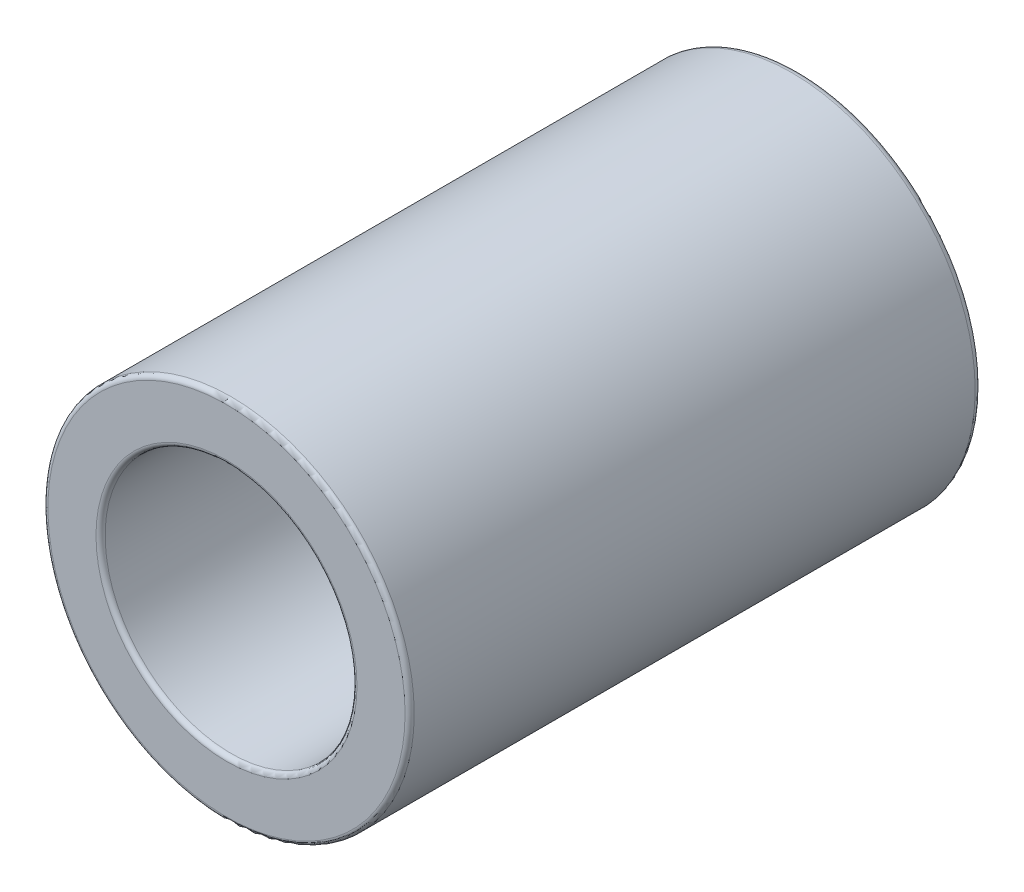
from build123d import *

# Parameters (mm, degrees)
SKETCH1_R           = 8
BOSS_EXTRUDE1_DEPTH = 25
SKETCH2_R           = 5.5
CUT_EXTRUDE1_DEPTH  = 20
SKETCH3_R           = 2.5
CUT_EXTRUDE2_DEPTH  = 6
FILLET1_R           = 0.2
FILLET2_R           = 0.3


with BuildPart() as part:
    # Sketch1 → Boss-Extrude1 (new body)
    with BuildSketch(Plane.XY):
        Circle(SKETCH1_R)
    extrude(amount=BOSS_EXTRUDE1_DEPTH)

    # Sketch2 → Cut-Extrude1 (cut)
    with BuildSketch(Plane.XY.offset(25)):
        Circle(SKETCH2_R)
    extrude(amount=-CUT_EXTRUDE1_DEPTH, mode=Mode.SUBTRACT)

    # Sketch3 → Cut-Extrude2 (cut, through all)
    with BuildSketch(Plane.XY.offset(5)):
        Circle(SKETCH3_R)
    extrude(amount=-CUT_EXTRUDE2_DEPTH, mode=Mode.SUBTRACT)

    # Fillet1
    fillet1_edges = [part.edges().sort_by_distance(p)[0] for p in [
        (-2.5, 0, 0),
        (-2.5, 0, 5),
        (-8, 0, 25),
        (-5.5, 0, 25),
    ]]
    fillet(fillet1_edges, radius=FILLET1_R)

    # Fillet2
    fillet2_edges = [part.edges().sort_by_distance(p)[0] for p in [
        (-8, 0, 0),
    ]]
    fillet(fillet2_edges, radius=FILLET2_R)


solid = part.part
